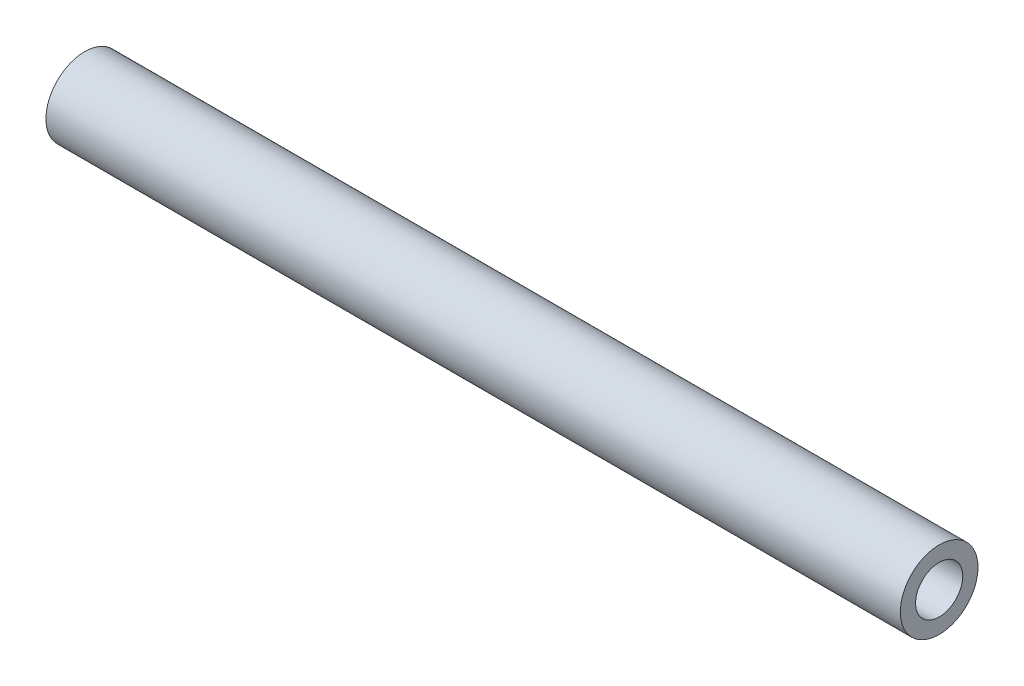
from build123d import *

# Parameters (mm, degrees)
SKETCH1_R           = 3.175
SKETCH1_R_2         = 1.9304
BOSS_EXTRUDE1_DEPTH = 34.925


with BuildPart() as part:
    # Sketch1 → Boss-Extrude1 (new body, symmetric)
    with BuildSketch(Plane(origin=(0, 0, 0), x_dir=(0, 0, -1), z_dir=(1, 0, 0))):
        Circle(SKETCH1_R)
        Circle(SKETCH1_R_2, mode=Mode.SUBTRACT)
    extrude(amount=BOSS_EXTRUDE1_DEPTH, both=True)


solid = part.part
